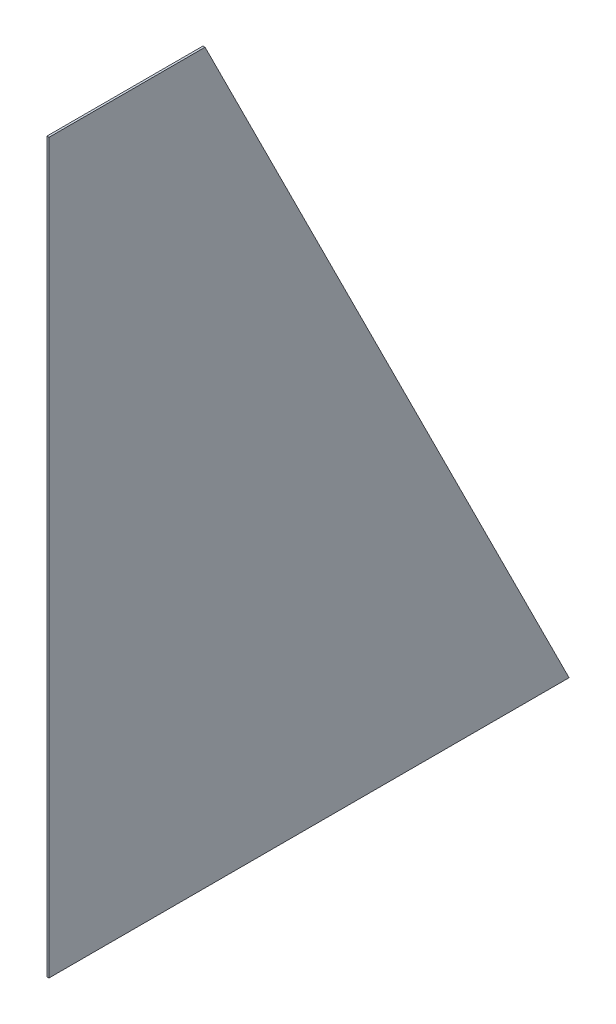
from build123d import *

# Parameters (mm, degrees)
EXTRUDE1_DEPTH      = 1
EXTRUDE1_DEPTH_BACK = 1


with BuildPart() as part:
    # Sketch1 → Extrude1 (new body, two sides)
    with BuildSketch(Plane(origin=(0, 0, 0), x_dir=(0, 0, -1), z_dir=(1, 0, 0))) as extrude1_sk:
        Polygon((0, 0), (0, 700), (150, 700), (500, 0), align=None)
    extrude(amount=EXTRUDE1_DEPTH)
    extrude(extrude1_sk.sketch, amount=-EXTRUDE1_DEPTH_BACK)


solid = part.part
